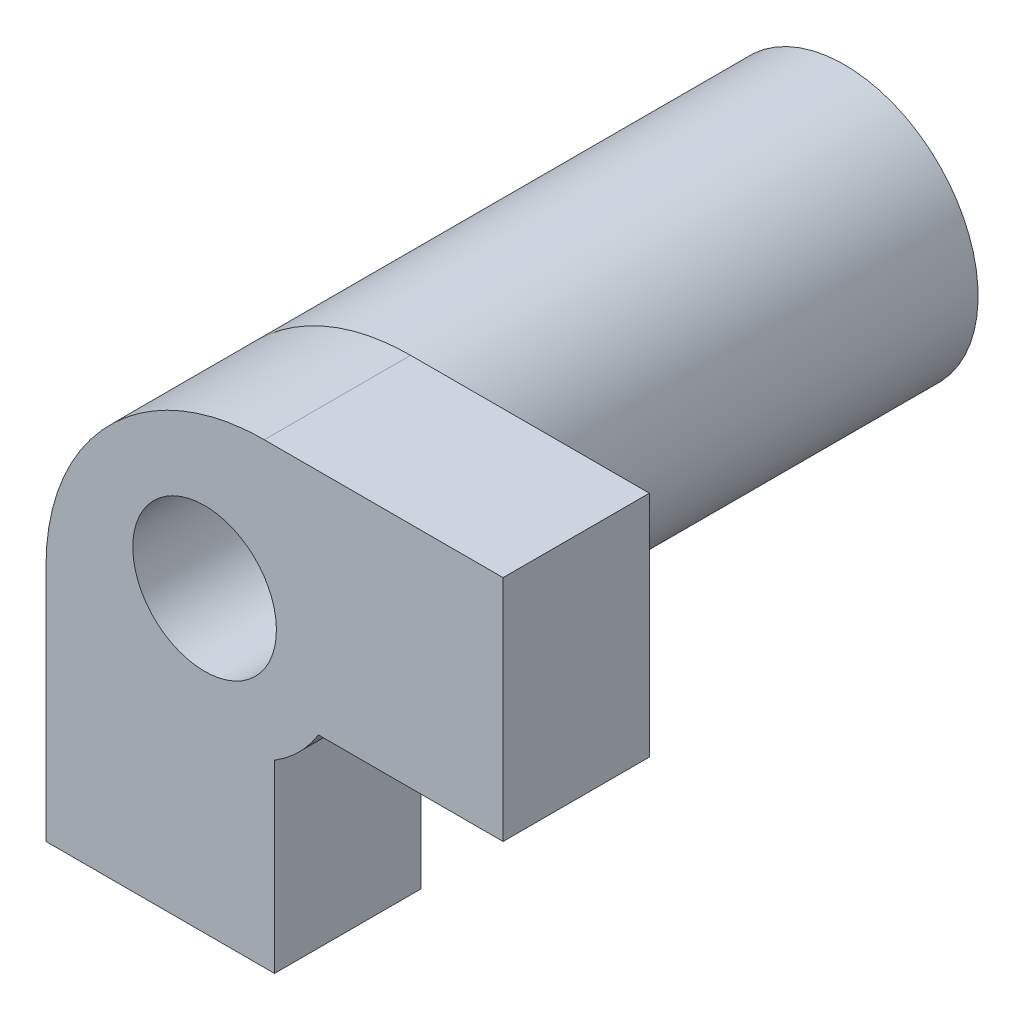
from build123d import *

# Parameters (mm, degrees)
SALIENTE_EXTRUIR1_DEPTH = 3.2
CROQUIS2_R              = 2.9227085
SALIENTE_EXTRUIR2_DEPTH = 10.8
CROQUIS3_R              = 1.571228252
CORTAR_EXTRUIR1_DEPTH   = 13.8
CORTAR_EXTRUIR2_DEPTH   = 13.8


with BuildPart() as part:
    # Model → Saliente-Extruir1 (new body)
    with BuildSketch(Plane.XY):
        with BuildLine():
            Line((-3.452848132, -1.30644903), (-3.452848132, -6.530212538))
            Line((-3.452848132, -6.530212538), (6.547151868, -6.530212538))
            Line((6.547151868, -6.530212538), (6.547151868, 3.469787462))
            Line((6.547151868, 3.469787462), (1.32338836, 3.469787462))
            add(Edge.make_bspline(
                [(-3.452848132, -1.30644903), (-3.452848132, 1.32052565), (-1.303487189, 3.469787462), (1.32338836, 3.469787462)],
                knots=[0.777777778, 0.777777778, 0.777777778, 0.777777778, 1, 1, 1, 1], degree=3))
        make_face()
        with BuildLine():
            add(Edge.make_bspline(
                [(0.016741068, 1.571228252), (-2.704706095, 1.571228252), (-1.343982514, -0.785614126), (0.016741068, -3.142456504), (1.377464649, -0.785614126), (2.73818823, 1.571228252), (0.016741068, 1.571228252)],
                knots=[0, 0, 0, 2.094395102, 2.094395102, 4.188790205, 4.188790205, 6.283185307, 6.283185307, 6.283185307], degree=2, weights=[1, 0.5, 1, 0.5, 1, 0.5, 1]))
        make_face(mode=Mode.SUBTRACT)
    extrude(amount=SALIENTE_EXTRUIR1_DEPTH)

    # Croquis2 → Saliente-Extruir2 (add)
    with BuildSketch(Plane(origin=(0, 0, 0), x_dir=(-1, 0, 0), z_dir=(0, 0, -1))):
        with Locations((-0.016741068, 0)):
            Circle(CROQUIS2_R)
    extrude(amount=SALIENTE_EXTRUIR2_DEPTH)

    # Croquis3 → Cortar-Extruir1 (cut)
    with BuildSketch(Plane.XY):
        with Locations((0.016741068, 0)):
            Circle(CROQUIS3_R)
    extrude(amount=-CORTAR_EXTRUIR1_DEPTH, mode=Mode.SUBTRACT)

    # Croquis4 → Cortar-Extruir2 (cut)
    with BuildSketch(Plane(origin=(0, 0, 0), x_dir=(-1, 0, 0), z_dir=(0, 0, -1))):
        with BuildLine():
            Line((-13.440411088, -13.370534454), (-1.547151868, -13.370534454))
            Line((-1.547151868, -13.370534454), (-1.547151868, -2.489993526))
            ThreePointArc((-1.547151868, -2.489993526), (-2.083490341, -2.066584722), (-2.506856439, -1.530212538))
            Line((-2.506856439, -1.530212538), (-13.440411088, -1.530212538))
            Line((-13.440411088, -1.530212538), (-13.440411088, -13.370534454))
        make_face()
    extrude(amount=-CORTAR_EXTRUIR2_DEPTH, mode=Mode.SUBTRACT)


solid = part.part
